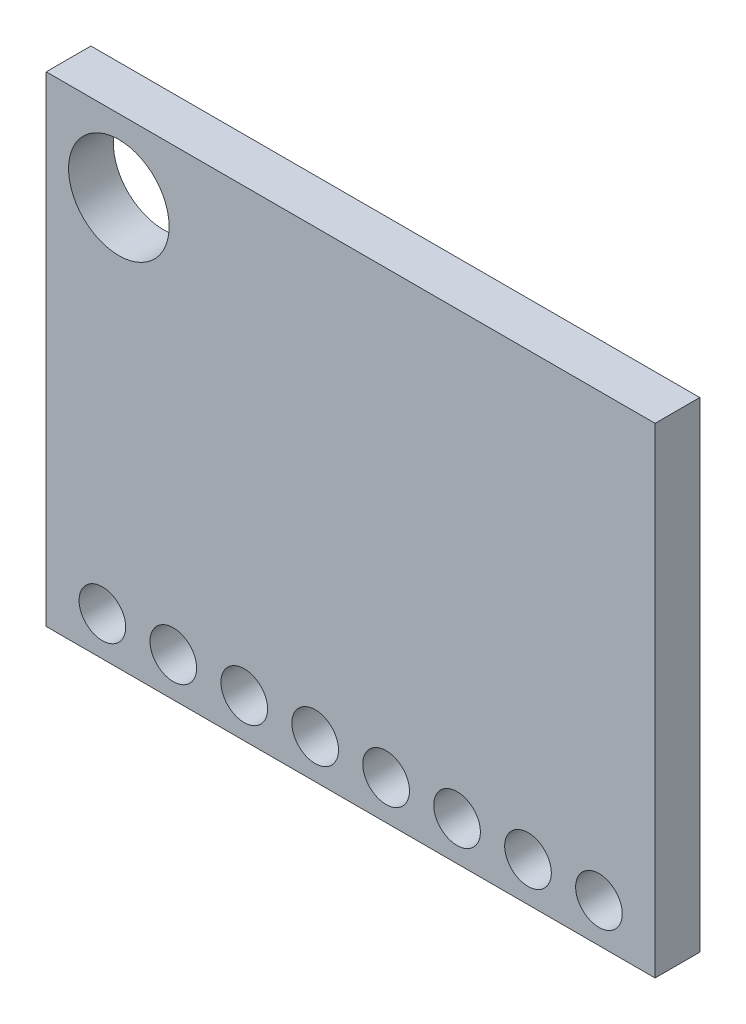
from build123d import *

# Parameters (mm, degrees)
SKETCH1_W           = 21.8
SKETCH1_H           = 17.2
BOSS_EXTRUDE1_DEPTH = 1.6
SKETCH2_R           = 0.835
SKETCH2_R_2         = 1.8
CUT_EXTRUDE1_DEPTH  = 1.6


with BuildPart() as part:
    # Sketch1 → Boss-Extrude1 (new body)
    with BuildSketch(Plane.XY):
        Rectangle(SKETCH1_W, SKETCH1_H)
    extrude(amount=BOSS_EXTRUDE1_DEPTH)

    # Sketch2 → Cut-Extrude1 (cut)
    with BuildSketch(Plane.XY.offset(1.6)):
        with Locations((8.89, -7.2)):
            Circle(SKETCH2_R)
        with Locations((6.35, -7.2)):
            Circle(SKETCH2_R)
        with Locations((3.81, -7.2)):
            Circle(SKETCH2_R)
        with Locations((1.27, -7.2)):
            Circle(SKETCH2_R)
        with Locations((-1.27, -7.2)):
            Circle(SKETCH2_R)
        with Locations((-3.81, -7.2)):
            Circle(SKETCH2_R)
        with Locations((-6.35, -7.2)):
            Circle(SKETCH2_R)
        with Locations((-8.89, -7.2)):
            Circle(SKETCH2_R)
        with Locations((-8.3, 6)):
            Circle(SKETCH2_R_2)
    extrude(amount=-CUT_EXTRUDE1_DEPTH, mode=Mode.SUBTRACT)


solid = part.part
